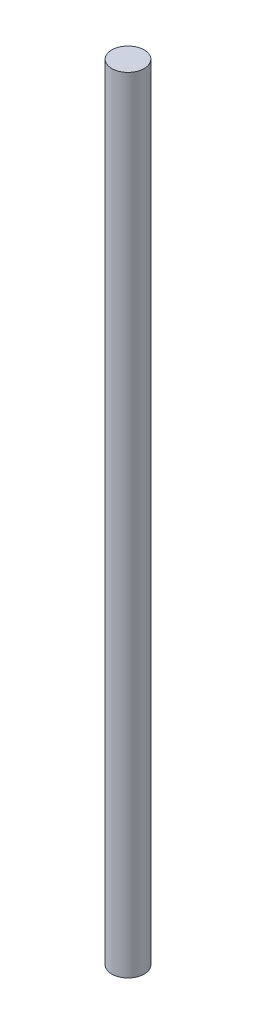
from build123d import *

# Parameters (mm, degrees)
SKETCH1_R           = 2
BOSS_EXTRUDE1_DEPTH = 97


with BuildPart() as part:
    # Sketch1 → Boss-Extrude1 (new body)
    with BuildSketch(Plane(origin=(0, 0, 0), x_dir=(1, 0, 0), z_dir=(0, 1, 0))):
        Circle(SKETCH1_R)
    extrude(amount=BOSS_EXTRUDE1_DEPTH)


solid = part.part
